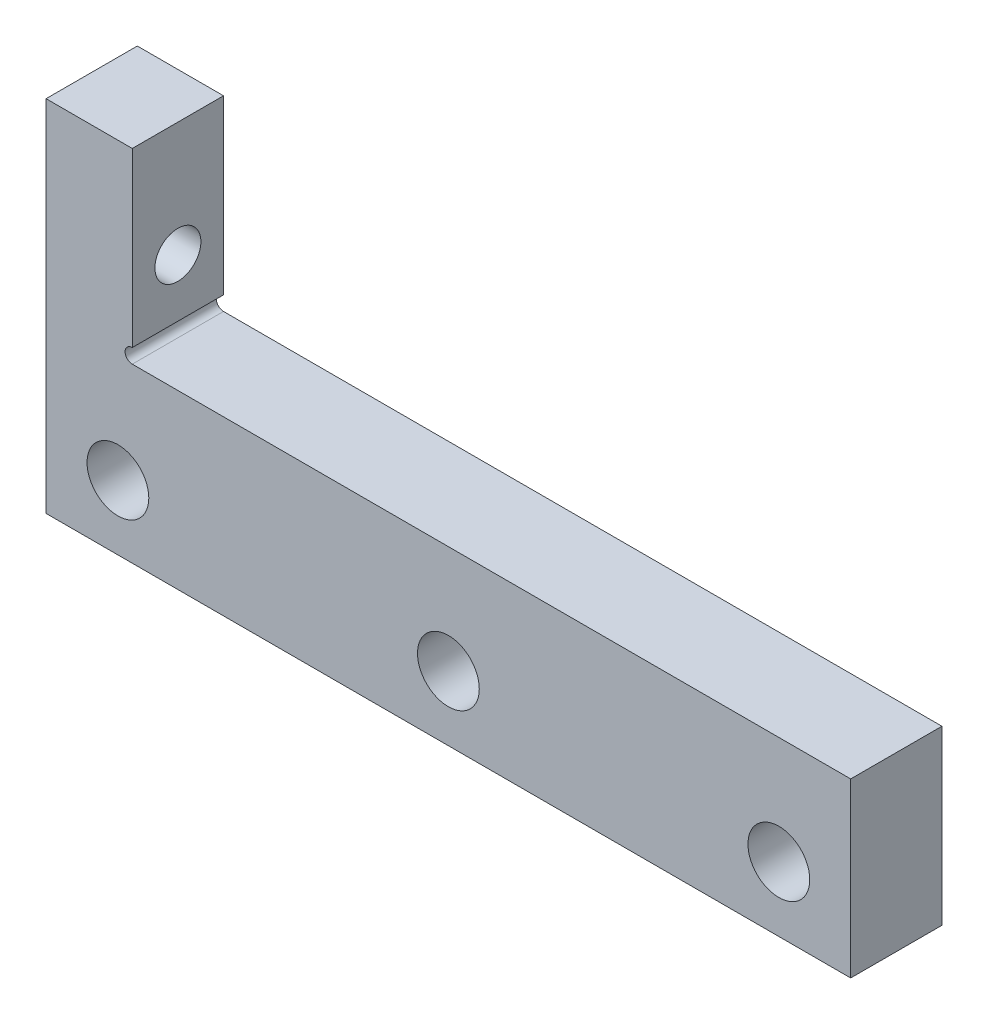
from build123d import *

# Parameters (mm, degrees)
SKETCH1_R                = 2.15
BOSS_EXTRUDE1_DEPTH      = 3.175
BOSS_EXTRUDE1_DEPTH_BACK = 3.175
CUT_EXTRUDE1_REACH       = 58
SKETCH2_R                = 1.6
SKETCH3_R                = 3
CUT_EXTRUDE2_DEPTH       = 2.5
SKETCH4_R                = 1.35
CUT_EXTRUDE3_DEPTH       = 5


with BuildPart() as part:
    # Sketch1 → Boss-Extrude1 (new body, two sides)
    with BuildSketch(Plane.XY) as boss_extrude1_sk:
        with BuildLine():
            Line((-70.5, 177.786291501), (-64.5, 177.786291501))
            Line((-64.5, 177.786291501), (-64.5, 165.786291501))
            ThreePointArc((-64.5, 165.786291501), (-65, 165.286291501), (-64.5, 164.786291501))
            Line((-64.5, 164.786291501), (-59.5, 164.786291501))
            Line((-59.5, 164.786291501), (-14.5, 164.786291501))
            Line((-14.5, 164.786291501), (-14.5, 152.786291501))
            Line((-14.5, 152.786291501), (-70.5, 152.786291501))
            Line((-70.5, 152.786291501), (-70.5, 177.786291501))
        make_face()
        with Locations((-65.5, 157.286291501)):
            Circle(SKETCH1_R, mode=Mode.SUBTRACT)
        with Locations((-42.5, 157.286291501)):
            Circle(SKETCH1_R, mode=Mode.SUBTRACT)
        with Locations((-19.5, 157.286291501)):
            Circle(SKETCH1_R, mode=Mode.SUBTRACT)
    extrude(amount=BOSS_EXTRUDE1_DEPTH)
    extrude(boss_extrude1_sk.sketch, amount=-BOSS_EXTRUDE1_DEPTH_BACK)

    # Sketch2 → Cut-Extrude1 (cut, up to next)
    with BuildSketch(Plane.ZY.offset(70.5), mode=Mode.PRIVATE) as cut_extrude1_sk1:
        with Locations((0, 169.786291501)):
            Circle(SKETCH2_R)
    cut_extrude1_tool1 = extrude(cut_extrude1_sk1.sketch, amount=-CUT_EXTRUDE1_REACH, mode=Mode.PRIVATE) & part.part
    add(cut_extrude1_tool1.solids().sort_by_distance((-70.5, 169.786292, 0))[0], mode=Mode.SUBTRACT)

    # Sketch3 → Cut-Extrude2 (cut)
    with BuildSketch(Plane.ZY.offset(70.5)):
        with Locations((0, 169.786291501)):
            Circle(SKETCH3_R)
    extrude(amount=-CUT_EXTRUDE2_DEPTH, mode=Mode.SUBTRACT)

    # Sketch4 → Cut-Extrude3 (cut)
    with BuildSketch(Plane.ZY.offset(70.5)):
        with Locations((0, 175.286291501)):
            Circle(SKETCH4_R)
        with Locations((0, 164.286291501)):
            Circle(SKETCH4_R)
    extrude(amount=-CUT_EXTRUDE3_DEPTH, mode=Mode.SUBTRACT)


solid = part.part
